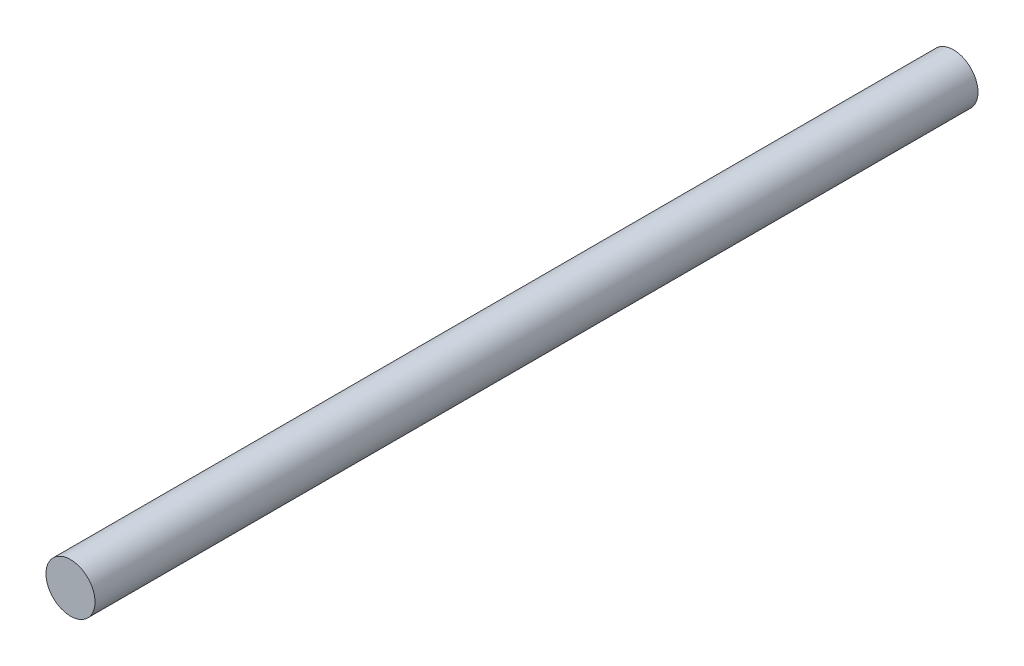
from build123d import *

# Parameters (mm, degrees)
SCHIZZO1_R                   = 1.25
ESTRUSIONE_ESTRUSIONE1_DEPTH = 45


with BuildPart() as part:
    # Schizzo1 → Estrusione-Estrusione1 (new body)
    with BuildSketch(Plane.XY):
        Circle(SCHIZZO1_R)
    extrude(amount=ESTRUSIONE_ESTRUSIONE1_DEPTH)


solid = part.part
